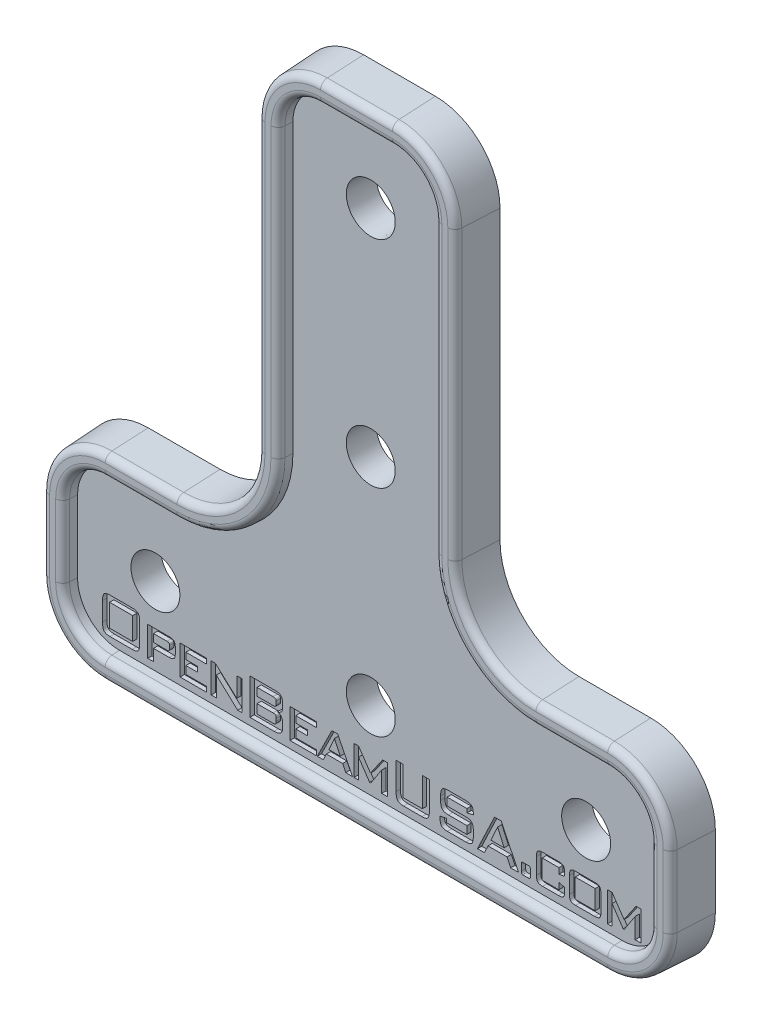
from build123d import *

# Parameters (mm, degrees)
BOSS_EXTRUDE1_DEPTH = 2
FILLET1_R           = 5
SKETCH2_R           = 1.6
CUT_EXTRUDE1_DEPTH  = 38.553295461
MOVE_FACE1_BY       = 0.5
MOVE_FACE1_2_BY     = 0.5
MOVE_FACE1_3_BY     = 0.5
MOVE_FACE1_4_BY     = 0.5
MOVE_FACE1_5_BY     = 0.5
MOVE_FACE1_6_BY     = 0.5
MOVE_FACE1_7_BY     = 0.5
MOVE_FACE1_8_BY     = 0.5
MOVE_FACE1_9_BY     = 0.5
MOVE_FACE1_10_BY    = 0.5
MOVE_FACE1_11_BY    = 0.5
MOVE_FACE1_12_BY    = 0.5
MOVE_FACE1_13_BY    = 0.5
MOVE_FACE1_14_BY    = 0.5
MOVE_FACE1_15_BY    = 0.5
MOVE_FACE1_16_BY    = 0.5
DRAFT1_ANGLE        = -3
BOSS_EXTRUDE3_DEPTH = 1
BOSS_EXTRUDE3_DRAFT = 3
FILLET3_R           = 0.5
CUT_EXTRUDE2_DEPTH  = 0.2
CUT_EXTRUDE2_DRAFT  = -3
SKETCH6_W           = 1.607142857
SKETCH6_H           = 1.5625
SKETCH6_W_2         = 1.383928571
SKETCH6_H_2         = 1.339285714
CUT_EXTRUDE3_DEPTH  = 0.3


with BuildPart() as part:
    # Sketch1 → Boss-Extrude1 (new body)
    with BuildSketch(Plane.XY):
        Polygon((-7.5, 30), (7.5, 30), (7.5, 0), (22.5, 0), (22.5, -15), (-22.5, -15), (-22.5, 0), (-7.5, 0), align=None)
    extrude(amount=BOSS_EXTRUDE1_DEPTH)

    # Fillet1
    fillet1_edges = [part.edges().sort_by_distance(p)[0] for p in [
        (-7.5, 30, 1),
        (7.5, 30, 1),
        (7.5, 0, 1),
        (22.5, 0, 1),
        (22.5, -15, 1),
        (-22.5, -15, 1),
        (-22.5, 0, 1),
        (-7.5, 0, 1),
    ]]
    fillet(fillet1_edges, radius=FILLET1_R)

    # Sketch2 → Cut-Extrude1 (cut, through all)
    with BuildSketch(Plane.XY.offset(2)):
        with Locations((-15, -7.5)):
            Circle(SKETCH2_R)
        with Locations((0, -7.5)):
            Circle(SKETCH2_R)
        with Locations((15, -7.5)):
            Circle(SKETCH2_R)
        with Locations((0, 22.5)):
            Circle(SKETCH2_R)
        with Locations((0, 7.5)):
            Circle(SKETCH2_R)
    extrude(amount=-CUT_EXTRUDE1_DEPTH, mode=Mode.SUBTRACT)

    # Move Face1: a curved face moved inward by 0.5
    add(Solid.thicken(part.faces().sort_by_distance((-8.964466094, 1.464466094, 1))[0], -MOVE_FACE1_BY), mode=Mode.SUBTRACT)

    # Move Face1 2: a face moved inward by 0.5
    extrude(part.faces().sort_by_distance((-15, 0, 1))[0], amount=MOVE_FACE1_2_BY, dir=(0, -1, 0), mode=Mode.SUBTRACT)

    # Move Face1 3: a curved face moved inward by 0.5
    add(Solid.thicken(part.faces().sort_by_distance((-21.035533906, -1.464466094, 1))[0], -MOVE_FACE1_3_BY), mode=Mode.SUBTRACT)

    # Move Face1 4: a face moved inward by 0.5
    extrude(part.faces().sort_by_distance((-22.5, -7.5, 1))[0], amount=MOVE_FACE1_4_BY, dir=(1, 0, 0), mode=Mode.SUBTRACT)

    # Move Face1 5: a curved face moved inward by 0.5
    add(Solid.thicken(part.faces().sort_by_distance((-21.035533906, -13.535533906, 1))[0], -MOVE_FACE1_5_BY), mode=Mode.SUBTRACT)

    # Move Face1 6: a face moved inward by 0.5
    extrude(part.faces().sort_by_distance((0, -15, 1))[0], amount=MOVE_FACE1_6_BY, dir=(0, 1, 0), mode=Mode.SUBTRACT)

    # Move Face1 7: a curved face moved inward by 0.5
    add(Solid.thicken(part.faces().sort_by_distance((21.035533906, -13.535533906, 1))[0], -MOVE_FACE1_7_BY), mode=Mode.SUBTRACT)

    # Move Face1 8: a face moved inward by 0.5
    extrude(part.faces().sort_by_distance((22.5, -7.5, 1))[0], amount=MOVE_FACE1_8_BY, dir=(-1, 0, 0), mode=Mode.SUBTRACT)

    # Move Face1 9: a curved face moved inward by 0.5
    add(Solid.thicken(part.faces().sort_by_distance((21.035533906, -1.464466094, 1))[0], -MOVE_FACE1_9_BY), mode=Mode.SUBTRACT)

    # Move Face1 10: a face moved inward by 0.5
    extrude(part.faces().sort_by_distance((15, 0, 1))[0], amount=MOVE_FACE1_10_BY, dir=(0, -1, 0), mode=Mode.SUBTRACT)

    # Move Face1 11: a curved face moved inward by 0.5
    add(Solid.thicken(part.faces().sort_by_distance((8.964466094, 1.464466094, 1))[0], -MOVE_FACE1_11_BY), mode=Mode.SUBTRACT)

    # Move Face1 12: a face moved inward by 0.5
    extrude(part.faces().sort_by_distance((7.5, 15, 1))[0], amount=MOVE_FACE1_12_BY, dir=(-1, 0, 0), mode=Mode.SUBTRACT)

    # Move Face1 13: a curved face moved inward by 0.5
    add(Solid.thicken(part.faces().sort_by_distance((6.035533906, 28.535533906, 1))[0], -MOVE_FACE1_13_BY), mode=Mode.SUBTRACT)

    # Move Face1 14: a face moved inward by 0.5
    extrude(part.faces().sort_by_distance((0, 30, 1))[0], amount=MOVE_FACE1_14_BY, dir=(0, -1, 0), mode=Mode.SUBTRACT)

    # Move Face1 15: a curved face moved inward by 0.5
    add(Solid.thicken(part.faces().sort_by_distance((-6.035533906, 28.535533906, 1))[0], -MOVE_FACE1_15_BY), mode=Mode.SUBTRACT)

    # Move Face1 16: a face moved inward by 0.5
    extrude(part.faces().sort_by_distance((-7.5, 15, 1))[0], amount=MOVE_FACE1_16_BY, dir=(1, 0, 0), mode=Mode.SUBTRACT)

    # Draft1
    draft1_faces = [part.faces().sort_by_distance(p)[0] for p in [
        (13.4, -7.5, 1),
        (-1.6, 22.5, 1),
        (-1.6, 7.5, 1),
        (-1.6, -7.5, 1),
        (-16.6, -7.5, 1),
        (-20.681980515, -1.818019485, 1),
        (-22, -7.5, 1),
        (-20.681980515, -13.181980515, 1),
        (0, -14.5, 1),
        (20.681980515, -13.181980515, 1),
        (22, -7.5, 1),
        (20.681980515, -1.818019485, 1),
        (15, -0.5, 1),
        (8.610912703, 1.110912703, 1),
        (7, 15, 1),
        (5.681980515, 28.181980515, 1),
        (0, 29.5, 1),
        (-5.681980515, 28.181980515, 1),
        (-7, 15, 1),
        (-8.610912703, 1.110912703, 1),
        (-15, -0.5, 1),
    ]]
    draft(draft1_faces, Plane(origin=(0, 0, 0), x_dir=(-1, 0, 0), z_dir=(0, 0, -1)), DRAFT1_ANGLE)


with BuildPart() as boss_extrude3_tool:
    # Sketch4 → Boss-Extrude3 (with draft: the straight prism first)
    with BuildSketch(Plane.XY.offset(2)):
        with BuildLine():
            Line((-17.5, -14.395184441), (17.5, -14.395184441))
            ThreePointArc((17.5, -14.395184441), (20.607864723, -13.107864723), (21.895184441, -10))
            Line((21.895184441, -10), (21.895184441, -5))
            ThreePointArc((21.895184441, -5), (20.607864723, -1.892135277), (17.5, -0.604815559))
            Line((17.5, -0.604815559), (12.5, -0.604815559))
            ThreePointArc((12.5, -0.604815559), (8.536796911, 1.036796911), (6.895184441, 5))
            Line((6.895184441, 5), (6.895184441, 25))
            ThreePointArc((6.895184441, 25), (5.607864723, 28.107864723), (2.5, 29.395184441))
            Line((2.5, 29.395184441), (-2.5, 29.395184441))
            ThreePointArc((-2.5, 29.395184441), (-5.607864723, 28.107864723), (-6.895184441, 25))
            Line((-6.895184441, 25), (-6.895184441, 5))
            ThreePointArc((-6.895184441, 5), (-8.536796911, 1.036796911), (-12.5, -0.604815559))
            Line((-12.5, -0.604815559), (-17.5, -0.604815559))
            ThreePointArc((-17.5, -0.604815559), (-20.607864723, -1.892135277), (-21.895184441, -5))
            Line((-21.895184441, -5), (-21.895184441, -10))
            ThreePointArc((-21.895184441, -10), (-20.607864723, -13.107864723), (-17.5, -14.395184441))
        make_face()
        with BuildLine():
            Line((-17.5, -12.921388331), (17.5, -12.921388331))
            ThreePointArc((17.5, -12.921388331), (19.565733499, -12.065733499), (20.421388331, -10))
            Line((20.421388331, -10), (20.421388331, -5))
            ThreePointArc((20.421388331, -5), (19.565733499, -2.934266501), (17.5, -2.078611669))
            Line((17.5, -2.078611669), (12.5, -2.078611669))
            ThreePointArc((12.5, -2.078611669), (7.494665688, -0.005334312), (5.421388331, 5))
            Line((5.421388331, 5), (5.421388331, 25))
            ThreePointArc((5.421388331, 25), (4.565733499, 27.065733499), (2.5, 27.921388331))
            Line((2.5, 27.921388331), (-2.5, 27.921388331))
            ThreePointArc((-2.5, 27.921388331), (-4.565733499, 27.065733499), (-5.421388331, 25))
            Line((-5.421388331, 25), (-5.421388331, 5))
            ThreePointArc((-5.421388331, 5), (-7.494665688, -0.005334312), (-12.5, -2.078611669))
            Line((-12.5, -2.078611669), (-17.5, -2.078611669))
            ThreePointArc((-17.5, -2.078611669), (-19.565733499, -2.934266501), (-20.421388331, -5))
            Line((-20.421388331, -5), (-20.421388331, -10))
            ThreePointArc((-20.421388331, -10), (-19.565733499, -12.065733499), (-17.5, -12.921388331))
        make_face(mode=Mode.SUBTRACT)
    extrude(amount=BOSS_EXTRUDE3_DEPTH)
    # Boss-Extrude3: the draft: its side faces are tilted about the plane it starts from
    boss_extrude3_sides = [boss_extrude3_tool.faces().sort_by_distance(p)[0] for p in [
        (-20.607864723, -1.892135277, 2.5),
        (-21.895184441, -7.5, 2.5),
        (-20.607864723, -13.107864723, 2.5),
        (0, -14.395184441, 2.5),
        (20.607864723, -13.107864723, 2.5),
        (21.895184441, -7.5, 2.5),
        (20.607864723, -1.892135277, 2.5),
        (15, -0.604815559, 2.5),
        (8.536796911, 1.036796911, 2.5),
        (6.895184441, 15, 2.5),
        (5.607864723, 28.107864723, 2.5),
        (0, 29.395184441, 2.5),
        (-5.607864723, 28.107864723, 2.5),
        (-6.895184441, 15, 2.5),
        (-8.536796911, 1.036796911, 2.5),
        (-15, -0.604815559, 2.5),
        (-15, -2.078611669, 2.5),
        (-7.494665688, -0.005334312, 2.5),
        (-5.421388331, 15, 2.5),
        (-4.565733499, 27.065733499, 2.5),
        (0, 27.921388331, 2.5),
        (4.565733499, 27.065733499, 2.5),
        (5.421388331, 15, 2.5),
        (7.494665688, -0.005334312, 2.5),
        (15, -2.078611669, 2.5),
        (19.565733499, -2.934266501, 2.5),
        (20.421388331, -7.5, 2.5),
        (19.565733499, -12.065733499, 2.5),
        (0, -12.921388331, 2.5),
        (-19.565733499, -12.065733499, 2.5),
        (-20.421388331, -7.5, 2.5),
        (-19.565733499, -2.934266501, 2.5),
    ]]
    draft(boss_extrude3_sides, Plane.XY.offset(2), BOSS_EXTRUDE3_DRAFT)


with BuildPart() as part_1:
    add(part.part)

    # Boss-Extrude3: add boss_extrude3_tool
    add(boss_extrude3_tool.part)

    # Fillet3
    fillet3_edges = [part_1.edges().sort_by_distance(p)[0] for p in [
        (-20.570806827, -13.070806827, 3),
        (0, -14.342776662, 3),
        (20.570806827, -13.070806827, 3),
        (21.842776662, -7.5, 3),
        (20.570806827, -1.929193173, 3),
        (15, -0.657223338, 3),
        (8.499739015, 0.999739015, 3),
        (6.842776662, 15, 3),
        (5.570806827, 28.070806827, 3),
        (0, 29.342776662, 3),
        (-5.570806827, 28.070806827, 3),
        (-6.842776662, 15, 3),
        (-8.499739015, 0.999739015, 3),
        (-15, -0.657223338, 3),
        (-20.570806827, -1.929193173, 3),
        (-21.842776662, -7.5, 3),
        (-19.602791396, -12.102791396, 3),
        (0, -12.97379611, 3),
        (19.602791396, -12.102791396, 3),
        (20.47379611, -7.5, 3),
        (19.602791396, -2.897208604, 3),
        (15, -2.02620389, 3),
        (7.531723584, 0.031723584, 3),
        (5.47379611, 15, 3),
        (4.602791396, 27.102791396, 3),
        (0, 27.97379611, 3),
        (-4.602791396, 27.102791396, 3),
        (-5.47379611, 15, 3),
        (-7.531723584, 0.031723584, 3),
        (-15, -2.02620389, 3),
        (-19.602791396, -2.897208604, 3),
        (-20.47379611, -7.5, 3),
    ]]
    fillet(fillet3_edges, radius=FILLET3_R)


with BuildPart() as cut_extrude2_tool:
    # Sketch5 → Cut-Extrude2 (with draft: the straight prism first)
    with BuildSketch(Plane(origin=(0, 0, 0), x_dir=(-1, 0, 0), z_dir=(0, 0, -1))):
        with BuildLine():
            Line((-14.5, -13.8), (14.5, -13.8))
            ThreePointArc((14.5, -13.8), (14.853553391, -13.653553391), (15, -13.3))
            Line((15, -13.3), (15, -10.3))
            ThreePointArc((15, -10.3), (14.853553391, -9.946446609), (14.5, -9.8))
            Line((14.5, -9.8), (-14.5, -9.8))
            ThreePointArc((-14.5, -9.8), (-14.853553391, -9.946446609), (-15, -10.3))
            Line((-15, -10.3), (-15, -13.3))
            ThreePointArc((-15, -13.3), (-14.853553391, -13.653553391), (-14.5, -13.8))
        make_face()
    extrude(amount=-CUT_EXTRUDE2_DEPTH)
    # Cut-Extrude2: the draft: its side faces are tilted about the plane it starts from
    cut_extrude2_sides = [cut_extrude2_tool.faces().sort_by_distance(p)[0] for p in [
        (0, -13.8, 0.1),
        (-14.853553391, -13.653553391, 0.1),
        (-15, -11.8, 0.1),
        (-14.853553391, -9.946446609, 0.1),
        (0, -9.8, 0.1),
        (14.853553391, -9.946446609, 0.1),
        (15, -11.8, 0.1),
        (14.853553391, -13.653553391, 0.1),
    ]]
    draft(cut_extrude2_sides, Plane(origin=(0, 0, 0), x_dir=(-1, 0, 0), z_dir=(0, 0, -1)), CUT_EXTRUDE2_DRAFT)


with BuildPart() as part_2:
    add(part_1.part)

    # Cut-Extrude2: cut by cut_extrude2_tool
    add(cut_extrude2_tool.part, mode=Mode.SUBTRACT)

    # Sketch6 → Cut-Extrude3 (cut)
    with BuildSketch(Plane.XY.offset(2)):
        with BuildLine():
            add(Edge.make_bspline(
                [(-18.683035714, -10.51011601), (-18.682938002, -10.482896819), (-18.682750693, -10.430719031), (-18.676668044, -10.356042819), (-18.668860697, -10.287926096), (-18.656684431, -10.226526586), (-18.643031263, -10.171215857), (-18.623628363, -10.123356935), (-18.602261682, -10.081592118), (-18.57683028, -10.045679654), (-18.545847467, -10.01549167), (-18.508789269, -9.990400409), (-18.46597857, -9.968617372), (-18.416580048, -9.951568957), (-18.361320255, -9.937537726), (-18.299893333, -9.928095322), (-18.232289845, -9.922620499), (-18.185232384, -9.921811984), (-18.160574777, -9.921388331)],
                knots=[0, 0, 0, 0, 1.403573437, 2.690578007, 3.862923789, 4.937964027, 5.918444779, 6.796020214, 7.595440406, 8.334448064, 9.055422419, 9.814027648, 10.634759978, 11.526322857, 12.50379092, 13.57259004, 14.728063101, 16, 16, 16, 16], degree=3))
            Line((-18.160574777, -9.921388331), (-16.618303571, -9.921388331))
            add(Edge.make_bspline(
                [(-16.618303571, -9.921388331), (-16.593646851, -9.921821445), (-16.546359359, -9.922652086), (-16.47851397, -9.928042886), (-16.416866585, -9.937552288), (-16.361581808, -9.951531158), (-16.312067564, -9.968807094), (-16.268818434, -9.990195221), (-16.231663242, -10.015520924), (-16.200589368, -10.045644028), (-16.175401388, -10.081803336), (-16.152770043, -10.122971899), (-16.134936302, -10.1715459), (-16.119750579, -10.226353255), (-16.108035577, -10.28796068), (-16.100083866, -10.356032245), (-16.094044728, -10.430722068), (-16.09385104, -10.48289786), (-16.09375, -10.51011601)],
                knots=[0, 0, 0, 0, 1.269785572, 2.435237667, 3.502229043, 4.478043838, 5.368098746, 6.198135559, 6.9554577, 7.675212615, 8.41297033, 9.216677895, 10.088421144, 11.070387939, 12.143609877, 13.313972779, 14.598800537, 16, 16, 16, 16], degree=3))
            Line((-16.09375, -10.51011601), (-16.09375, -11.811036769))
            add(Edge.make_bspline(
                [(-16.09375, -11.811036769), (-16.093842278, -11.839417739), (-16.09401872, -11.893684241), (-16.100160957, -11.971615929), (-16.107923834, -12.042494992), (-16.119768025, -12.106636793), (-16.134983627, -12.163512713), (-16.152647685, -12.213987832), (-16.175226782, -12.256626432), (-16.200584268, -12.293600425), (-16.231614851, -12.324447097), (-16.268765478, -12.35050105), (-16.312034652, -12.372539497), (-16.361440049, -12.390711436), (-16.416882029, -12.404519647), (-16.478547615, -12.413833116), (-16.546317858, -12.420380788), (-16.593639586, -12.421043123), (-16.618303571, -12.421388331)],
                knots=[0, 0, 0, 0, 1.431764632, 2.737639174, 3.942781974, 5.02906717, 6.025299976, 6.912532689, 7.72083079, 8.453349384, 9.16691991, 9.91579719, 10.734504626, 11.610727997, 12.566975227, 13.612570717, 14.755676853, 16, 16, 16, 16], degree=3))
            Line((-16.618303571, -12.421388331), (-18.160574777, -12.421388331))
            add(Edge.make_bspline(
                [(-18.160574777, -12.421388331), (-18.185239843, -12.421053786), (-18.232332055, -12.420415051), (-18.299858951, -12.413778337), (-18.36130513, -12.404534983), (-18.416721056, -12.39067324), (-18.466016648, -12.372733543), (-18.508837175, -12.350292386), (-18.545896228, -12.324476536), (-18.576835987, -12.293565989), (-18.602437267, -12.256831275), (-18.623739569, -12.213611433), (-18.642993476, -12.163833364), (-18.656664691, -12.106469119), (-18.668974999, -12.042529082), (-18.676590443, -11.971605588), (-18.682776858, -11.893687213), (-18.682946824, -11.83941876), (-18.683035714, -11.811036769)],
                knots=[0, 0, 0, 0, 1.246375741, 2.37966474, 3.42698501, 4.384809634, 5.262478393, 6.072109836, 6.82222244, 7.536970048, 8.27069698, 9.074935671, 9.967741802, 10.962637047, 12.050714143, 13.257844907, 14.565873577, 16, 16, 16, 16], degree=3))
            Line((-18.683035714, -11.811036769), (-18.683035714, -10.51011601))
        make_face()
        with Locations((-17.388392858, -11.149066903)):
            Rectangle(SKETCH6_W, SKETCH6_H, mode=Mode.SUBTRACT)
        with BuildLine():
            Line((-15.535714286, -12.421388331), (-15.535714286, -10.367816903))
            Line((-15.535714286, -10.367816903), (-14.029715402, -10.367816903))
            add(Edge.make_bspline(
                [(-14.029715402, -10.367816903), (-13.995423097, -10.368539056), (-13.931618582, -10.369882701), (-13.843548193, -10.388389773), (-13.76975323, -10.416602804), (-13.710808728, -10.459570634), (-13.666606985, -10.516609772), (-13.63694694, -10.588263693), (-13.619168575, -10.67387452), (-13.617150642, -10.735791272), (-13.616071429, -10.768905072)],
                knots=[0, 0, 0, 0, 1.229947315, 2.288449038, 3.21776736, 4.048244043, 4.875520742, 5.777278643, 6.811262717, 8, 8, 8, 8], degree=3))
            Line((-13.616071429, -10.768905072), (-13.616071429, -11.216728733))
            add(Edge.make_bspline(
                [(-13.616071429, -11.216728733), (-13.61713941, -11.249840567), (-13.619129003, -11.311526162), (-13.637004149, -11.397243648), (-13.667259143, -11.468686782), (-13.711509006, -11.52635012), (-13.770938209, -11.568616699), (-13.844372756, -11.597454165), (-13.932113653, -11.615653184), (-13.995666115, -11.617062069), (-14.029715402, -11.617816903)],
                knots=[0, 0, 0, 0, 1.189703839, 2.216355318, 3.129857055, 3.957806409, 4.795702339, 5.718039216, 6.7774016, 8, 8, 8, 8], degree=3))
            Line((-14.029715402, -11.617816903), (-15.133928571, -11.617816903))
            Line((-15.133928571, -11.617816903), (-15.133928571, -12.421388331))
            Line((-15.133928571, -12.421388331), (-15.535714286, -12.421388331))
        make_face()
        with BuildLine():
            Line((-14.203404018, -10.72495976), (-15.133928571, -10.72495976))
            Line((-15.133928571, -10.72495976), (-15.133928571, -11.260674045))
            Line((-15.133928571, -11.260674045), (-14.203404018, -11.260674045))
            add(Edge.make_bspline(
                [(-14.203404018, -11.260674045), (-14.187098835, -11.260411914), (-14.157096885, -11.259929586), (-14.115874448, -11.253123203), (-14.082698889, -11.241865943), (-14.056496441, -11.22503593), (-14.038862603, -11.201230006), (-14.025790126, -11.172314024), (-14.019621299, -11.136752914), (-14.018473493, -11.11118051), (-14.017857143, -11.097448599)],
                knots=[0, 0, 0, 0, 1.352116432, 2.487928597, 3.45245427, 4.244622693, 5.028283095, 5.874769735, 6.858790467, 8, 8, 8, 8], degree=3))
            Line((-14.017857143, -11.097448599), (-14.017857143, -10.888185206))
            add(Edge.make_bspline(
                [(-14.017857143, -10.888185206), (-14.018466943, -10.874447349), (-14.01960255, -10.848863871), (-14.025849613, -10.813373783), (-14.038604854, -10.784405633), (-14.05696494, -10.76134583), (-14.082395639, -10.743581231), (-14.115935147, -10.732589069), (-14.157077073, -10.725678609), (-14.187091859, -10.725212873), (-14.203404018, -10.72495976)],
                knots=[0, 0, 0, 0, 1.141800926, 2.126331593, 2.973256896, 3.742199929, 4.545756613, 5.510782118, 6.64718288, 8, 8, 8, 8], degree=3))
        make_face(mode=Mode.SUBTRACT)
        Polygon((-13.28125, -12.421388331), (-13.28125, -10.367816903), (-11.450892857, -10.367816903), (-11.450892857, -10.72495976), (-12.879464286, -10.72495976), (-12.879464286, -11.171388331), (-12.075892857, -11.171388331), (-12.075892857, -11.528531188), (-12.879464286, -11.528531188), (-12.879464286, -12.064245474), (-11.450892857, -12.064245474), (-11.450892857, -12.421388331), align=None)
        Polygon((-11.116071429, -12.421388331), (-11.116071429, -10.367816903), (-10.821707589, -10.367816903), (-9.330357143, -11.731516679), (-9.330357143, -10.367816903), (-8.973214286, -10.367816903), (-8.973214286, -12.421388331), (-9.269670759, -12.421388331), (-10.758928571, -11.036762215), (-10.758928571, -12.421388331), align=None)
        with BuildLine():
            Line((-8.415178571, -12.421388331), (-8.415178571, -9.921388331))
            Line((-8.415178571, -9.921388331), (-6.604352679, -9.921388331))
            add(Edge.make_bspline(
                [(-6.604352679, -9.921388331), (-6.584578843, -9.921834875), (-6.546344475, -9.922698306), (-6.490993159, -9.928039701), (-6.439967327, -9.937982556), (-6.392984602, -9.950745963), (-6.350485334, -9.96859511), (-6.312122888, -9.989884555), (-6.278270641, -10.015636971), (-6.247499297, -10.044225626), (-6.221859971, -10.078333565), (-6.199342826, -10.116212883), (-6.180626562, -10.158719559), (-6.16430305, -10.205449169), (-6.152784019, -10.257462736), (-6.1448266, -10.313921043), (-6.13872257, -10.37466268), (-6.138505034, -10.416628349), (-6.138392857, -10.438268911)],
                knots=[0, 0, 0, 0, 1.179053587, 2.27979888, 3.310209753, 4.275627239, 5.176695408, 6.051906754, 6.883661987, 7.707291014, 8.547436998, 9.417583548, 10.329674368, 11.311670144, 12.364223081, 13.499348066, 14.710481303, 16, 16, 16, 16], degree=3))
            Line((-6.138392857, -10.438268911), (-6.138392857, -10.712403956))
            add(Edge.make_bspline(
                [(-6.138392857, -10.712403956), (-6.139201585, -10.740664602), (-6.140751158, -10.794813763), (-6.159801787, -10.871364096), (-6.188653758, -10.939999278), (-6.231476997, -10.9984646), (-6.284875183, -11.04779488), (-6.349361396, -11.086101447), (-6.424010981, -11.11446387), (-6.477873721, -11.124365422), (-6.505998884, -11.129535653)],
                knots=[0, 0, 0, 0, 1.098733523, 2.105242008, 3.054667811, 3.982622784, 4.906010345, 5.869427447, 6.887492557, 8, 8, 8, 8], degree=3))
            add(Edge.make_bspline(
                [(-6.505998884, -11.129535653), (-6.478036354, -11.135503517), (-6.424069928, -11.147021228), (-6.349494996, -11.180530422), (-6.285840082, -11.227562783), (-6.231981261, -11.286146859), (-6.190215279, -11.356411535), (-6.158931917, -11.436113578), (-6.142041656, -11.526206522), (-6.139644104, -11.589151907), (-6.138392857, -11.62200217)],
                knots=[0, 0, 0, 0, 1.013460027, 1.955932307, 2.877588656, 3.806945104, 4.76292404, 5.764334755, 6.833239427, 8, 8, 8, 8], degree=3))
            Line((-6.138392857, -11.62200217), (-6.138392857, -11.935199715))
            add(Edge.make_bspline(
                [(-6.138392857, -11.935199715), (-6.138719134, -11.95521589), (-6.1393511, -11.993985259), (-6.146352988, -12.050089823), (-6.158290901, -12.101885834), (-6.174184983, -12.150022339), (-6.195462804, -12.19402501), (-6.220131016, -12.234909748), (-6.250938229, -12.270878361), (-6.285794672, -12.303013122), (-6.32562112, -12.331371608), (-6.370173139, -12.355556185), (-6.41960395, -12.375811734), (-6.47355595, -12.392422759), (-6.532276629, -12.405800235), (-6.595779264, -12.414401622), (-6.66400309, -12.420183393), (-6.71106383, -12.420976607), (-6.735491071, -12.421388331)],
                knots=[0, 0, 0, 0, 1.08782081, 2.107002258, 3.066832627, 3.974287218, 4.856380914, 5.719335199, 6.562621095, 7.421491684, 8.291454475, 9.213583009, 10.171413382, 11.190986747, 12.279688622, 13.441734262, 14.672112383, 16, 16, 16, 16], degree=3))
            Line((-6.735491071, -12.421388331), (-8.415178571, -12.421388331))
        make_face()
        with BuildLine():
            Line((-6.809430804, -10.367816903), (-7.924107143, -10.367816903))
            Line((-7.924107143, -10.367816903), (-7.924107143, -10.903531188))
            Line((-7.924107143, -10.903531188), (-6.809430804, -10.903531188))
            add(Edge.make_bspline(
                [(-6.809430804, -10.903531188), (-6.789868986, -10.903287406), (-6.753850642, -10.902838541), (-6.704705771, -10.895868934), (-6.664727575, -10.885532078), (-6.633451466, -10.869144346), (-6.610525171, -10.846199776), (-6.594844818, -10.816925235), (-6.585991347, -10.781273052), (-6.585228551, -10.755471654), (-6.584821429, -10.741700831)],
                knots=[0, 0, 0, 0, 1.458061766, 2.684667078, 3.694961047, 4.525618309, 5.286113602, 6.078010599, 6.974188284, 8, 8, 8, 8], degree=3))
            Line((-6.584821429, -10.741700831), (-6.584821429, -10.52964726))
            add(Edge.make_bspline(
                [(-6.584821429, -10.52964726), (-6.585215601, -10.516102183), (-6.585953486, -10.490746024), (-6.594997769, -10.455637651), (-6.610492176, -10.426504554), (-6.633624093, -10.40365479), (-6.664600507, -10.386469448), (-6.704601516, -10.375280427), (-6.753863487, -10.36857796), (-6.789873506, -10.368084762), (-6.809430804, -10.367816903)],
                knots=[0, 0, 0, 0, 1.011123078, 1.892805606, 2.686758123, 3.449227428, 4.290532683, 5.308364354, 6.538153555, 8, 8, 8, 8], degree=3))
        make_face(mode=Mode.SUBTRACT)
        with BuildLine():
            Line((-6.809430804, -11.34995976), (-7.924107143, -11.34995976))
            Line((-7.924107143, -11.34995976), (-7.924107143, -11.97495976))
            Line((-7.924107143, -11.97495976), (-6.809430804, -11.97495976))
            add(Edge.make_bspline(
                [(-6.809430804, -11.97495976), (-6.78912971, -11.974729537), (-6.751959866, -11.974308016), (-6.701848603, -11.964050408), (-6.661008099, -11.950556293), (-6.630050641, -11.927619568), (-6.609123919, -11.895827935), (-6.594863374, -11.856463039), (-6.585878103, -11.808409349), (-6.585191715, -11.773414396), (-6.584821429, -11.754535653)],
                knots=[0, 0, 0, 0, 1.312342557, 2.402804986, 3.304020979, 4.078546667, 4.847629795, 5.734752509, 6.777965855, 8, 8, 8, 8], degree=3))
            Line((-6.584821429, -11.754535653), (-6.584821429, -11.568291233))
            add(Edge.make_bspline(
                [(-6.584821429, -11.568291233), (-6.585200764, -11.549416114), (-6.585903926, -11.514427881), (-6.594743125, -11.466546068), (-6.609130884, -11.427679287), (-6.630070466, -11.396444881), (-6.661397726, -11.374656265), (-6.701546197, -11.359680216), (-6.752105393, -11.35100656), (-6.789165763, -11.350329813), (-6.809430804, -11.34995976)],
                knots=[0, 0, 0, 0, 1.227068129, 2.274578833, 3.151237288, 3.911086288, 4.679771909, 5.590123259, 6.682251448, 8, 8, 8, 8], degree=3))
        make_face(mode=Mode.SUBTRACT)
        Polygon((-5.625, -12.421388331), (-5.625, -10.367816903), (-3.794642857, -10.367816903), (-3.794642857, -10.72495976), (-5.223214286, -10.72495976), (-5.223214286, -11.171388331), (-4.419642857, -11.171388331), (-4.419642857, -11.528531188), (-5.223214286, -11.528531188), (-5.223214286, -12.064245474), (-3.794642857, -12.064245474), (-3.794642857, -12.421388331), align=None)
        Polygon((-3.727678571, -12.421388331), (-2.709263393, -10.367816903), (-2.306780134, -10.367816903), (-1.272321429, -12.421388331), (-1.741768973, -12.421388331), (-1.958007812, -11.97495976), (-3.093610491, -11.97495976), (-3.30984933, -12.421388331), align=None)
        Polygon((-2.915039062, -11.617816903), (-2.128208705, -11.617816903), (-2.52859933, -10.746583644), align=None, mode=Mode.SUBTRACT)
        Polygon((-1.160714286, -12.421388331), (-1.160714286, -10.367816903), (-0.848214286, -10.367816903), (-0.017438616, -11.586427394), (0.822405134, -10.367816903), (1.160714286, -10.367816903), (1.160714286, -12.421388331), (0.758928571, -12.421388331), (0.758928571, -11.008162885), (0.000697545, -12.174457528), (-0.080217634, -12.174457528), (-0.848214286, -11.040947483), (-0.848214286, -12.421388331), align=None)
        with BuildLine():
            Line((2.254464286, -9.921388331), (2.254464286, -11.930316903))
            Line((2.254464286, -11.930316903), (3.59375, -11.930316903))
            Line((3.59375, -11.930316903), (3.59375, -9.921388331))
            Line((3.59375, -9.921388331), (4.084821429, -9.921388331))
            Line((4.084821429, -9.921388331), (4.084821429, -11.811036769))
            add(Edge.make_bspline(
                [(4.084821429, -11.811036769), (4.084729151, -11.83941774), (4.08455271, -11.893684242), (4.078410469, -11.971615924), (4.070647603, -12.042495008), (4.058803376, -12.106636741), (4.043587889, -12.163512882), (4.025923466, -12.213987296), (4.003345545, -12.256628171), (3.977984177, -12.293594652), (3.946967658, -12.32446853), (3.909930317, -12.35029481), (3.867103299, -12.37273261), (3.817809766, -12.390674382), (3.762392801, -12.404530974), (3.700719574, -12.413829665), (3.632951625, -12.420381775), (3.585629562, -12.421043461), (3.560965402, -12.421388331)],
                knots=[0, 0, 0, 0, 1.432696721, 2.739421396, 3.945348753, 5.032341128, 6.029222489, 6.917032796, 7.725857105, 8.458852573, 9.172887639, 9.922252443, 10.731076752, 11.60787055, 12.564740304, 13.611016484, 14.75486679, 16, 16, 16, 16], degree=3))
            Line((3.560965402, -12.421388331), (2.28515625, -12.421388331))
            add(Edge.make_bspline(
                [(2.28515625, -12.421388331), (2.260725019, -12.421041479), (2.213867868, -12.420376245), (2.146787965, -12.413857345), (2.085611417, -12.404422129), (2.030586419, -12.390821903), (1.981612193, -12.372601766), (1.938902995, -12.350085944), (1.901310533, -12.324703811), (1.870249293, -12.29356777), (1.844862961, -12.25663627), (1.822292601, -12.2139848), (1.804625834, -12.16351367), (1.789411083, -12.106636498), (1.777566629, -12.042495084), (1.769803833, -11.971615901), (1.763661571, -11.893684249), (1.763485133, -11.839417742), (1.763392857, -11.811036769)],
                knots=[0, 0, 0, 0, 1.23621022, 2.370952548, 3.407995083, 4.367048021, 5.234819768, 6.045489481, 6.806183598, 7.521847799, 8.256515662, 9.067185375, 9.957021301, 10.956177136, 12.045649581, 13.254328369, 14.564034454, 16, 16, 16, 16], degree=3))
            Line((1.763392857, -11.811036769), (1.763392857, -9.921388331))
            Line((1.763392857, -9.921388331), (2.254464286, -9.921388331))
        make_face()
        with BuildLine():
            Line((6.696428571, -10.367816903), (5.3125, -10.367816903))
            Line((5.3125, -10.367816903), (5.3125, -10.903531188))
            Line((5.3125, -10.903531188), (6.63016183, -10.903531188))
            add(Edge.make_bspline(
                [(6.63016183, -10.903531188), (6.654353014, -10.903958949), (6.700479225, -10.904774577), (6.766713326, -10.910183332), (6.826905144, -10.919870583), (6.881304458, -10.93330079), (6.92929363, -10.951844001), (6.971690494, -10.973066465), (7.007619207, -10.999097146), (7.038065694, -11.029410299), (7.063642091, -11.06526319), (7.084974932, -11.107481732), (7.103195036, -11.156136605), (7.117397219, -11.211638562), (7.129343814, -11.273803544), (7.137366908, -11.3428083), (7.142315022, -11.418477621), (7.142671297, -11.471091459), (7.142857143, -11.498536769)],
                knots=[0, 0, 0, 0, 1.251664019, 2.386593346, 3.434812074, 4.403525499, 5.279339231, 6.091802716, 6.849802477, 7.564361493, 8.305564064, 9.118027549, 10.005088541, 10.988481401, 12.078528828, 13.278238635, 14.580229349, 16, 16, 16, 16], degree=3))
            Line((7.142857143, -11.498536769), (7.142857143, -11.820802394))
            add(Edge.make_bspline(
                [(7.142857143, -11.820802394), (7.142670907, -11.848480082), (7.142313758, -11.90155824), (7.137365743, -11.977924663), (7.1293358, -12.047622044), (7.117402599, -12.110490083), (7.103150126, -12.166658376), (7.085162413, -12.215888413), (7.063443653, -12.258367141), (7.038074605, -12.294750102), (7.0078556, -12.325841034), (6.971643631, -12.351775421), (6.929450865, -12.373242409), (6.881137779, -12.390741413), (6.826858606, -12.40421072), (6.766788679, -12.414980112), (6.70046859, -12.42007351), (6.654349355, -12.420935995), (6.63016183, -12.421388331)],
                knots=[0, 0, 0, 0, 1.424071459, 2.730975543, 3.936089492, 5.032008831, 6.021662612, 6.915142695, 7.723221153, 8.470166276, 9.189379185, 9.94328787, 10.751366328, 11.61825191, 12.581736995, 13.626287574, 14.755091461, 16, 16, 16, 16], degree=3))
            Line((6.63016183, -12.421388331), (5.324358259, -12.421388331))
            add(Edge.make_bspline(
                [(5.324358259, -12.421388331), (5.300866876, -12.420931359), (5.255674503, -12.420052242), (5.190533843, -12.414925726), (5.131530179, -12.404487117), (5.078393092, -12.390307101), (5.030932807, -12.373619972), (4.989668753, -12.35157881), (4.954294363, -12.325618915), (4.924073733, -12.294956748), (4.899449082, -12.258298175), (4.878544743, -12.215717937), (4.860436506, -12.166672042), (4.845991982, -12.110563995), (4.835216036, -12.047531968), (4.826837919, -11.97793932), (4.821995382, -11.901554055), (4.821622836, -11.848478648), (4.821428571, -11.820802394)],
                knots=[0, 0, 0, 0, 1.219667072, 2.346377425, 3.388230707, 4.325160294, 5.199674189, 5.993493179, 6.744299279, 7.46984103, 8.21646325, 9.026182912, 9.927525331, 10.925887746, 12.029274189, 13.244992753, 14.563397171, 16, 16, 16, 16], degree=3))
            Line((4.821428571, -11.820802394), (4.821428571, -11.75872092))
            Line((4.821428571, -11.75872092), (5.267857143, -11.66245976))
            Line((5.267857143, -11.66245976), (5.267857143, -11.930316903))
            Line((5.267857143, -11.930316903), (6.696428571, -11.930316903))
            Line((6.696428571, -11.930316903), (6.696428571, -11.394602617))
            Line((6.696428571, -11.394602617), (5.406668527, -11.394602617))
            add(Edge.make_bspline(
                [(5.406668527, -11.394602617), (5.381318621, -11.394142187), (5.332646449, -11.393258156), (5.262625271, -11.38820715), (5.199039968, -11.377517598), (5.141836488, -11.363824902), (5.090670769, -11.346784404), (5.046603427, -11.324170198), (5.008215836, -11.298389637), (4.97572848, -11.267778264), (4.949636871, -11.230568829), (4.926561464, -11.188113753), (4.907738712, -11.138304217), (4.89305814, -11.081840424), (4.880014688, -11.018833425), (4.872516201, -10.948772379), (4.866340152, -10.872018433), (4.86616349, -10.818446253), (4.866071429, -10.790528956)],
                knots=[0, 0, 0, 0, 1.269118906, 2.436725934, 3.510156791, 4.492522834, 5.379601377, 6.202018549, 6.963898946, 7.688320218, 8.421662355, 9.228867506, 10.102094215, 11.078998209, 12.147242463, 13.319481032, 14.603139802, 16, 16, 16, 16], degree=3))
            Line((4.866071429, -10.790528956), (4.866071429, -10.512906188))
            add(Edge.make_bspline(
                [(4.866071429, -10.512906188), (4.866168727, -10.485686466), (4.866356072, -10.43327569), (4.872507781, -10.358146186), (4.880016723, -10.289478223), (4.89301151, -10.227844707), (4.907893802, -10.172615002), (4.926346791, -10.123783283), (4.949852356, -10.082499353), (4.975700358, -10.04602468), (5.008481655, -10.016282414), (5.046389433, -9.990260801), (5.090887408, -9.968693775), (5.141807749, -9.951449339), (5.198979833, -9.937581032), (5.262701901, -9.928047641), (5.332635014, -9.922656793), (5.381314705, -9.921822734), (5.406668527, -9.921388331)],
                knots=[0, 0, 0, 0, 1.377632593, 2.652591195, 3.814954431, 4.872421982, 5.83787301, 6.710181857, 7.506051987, 8.238342604, 8.963022824, 9.733676968, 10.56030012, 11.457594181, 12.451273063, 13.535212947, 14.716266034, 16, 16, 16, 16], degree=3))
            Line((5.406668527, -9.921388331), (6.606445313, -9.921388331))
            add(Edge.make_bspline(
                [(6.606445313, -9.921388331), (6.630871508, -9.921807846), (6.677930234, -9.92261607), (6.745479683, -9.928236239), (6.807133727, -9.936888325), (6.862778268, -9.950065049), (6.91249593, -9.967560204), (6.956687775, -9.988232319), (6.995178384, -10.012838845), (7.027760105, -10.041925314), (7.055736906, -10.075759055), (7.07966266, -10.115155119), (7.098382083, -10.160900236), (7.115935242, -10.211649019), (7.127570867, -10.2686675), (7.13703729, -10.331263883), (7.141354413, -10.399846619), (7.142342132, -10.447566677), (7.142857143, -10.472448599)],
                knots=[0, 0, 0, 0, 1.296779316, 2.498333482, 3.59650498, 4.599589076, 5.528850417, 6.390279385, 7.1847031, 7.945414428, 8.699384315, 9.508162524, 10.381888205, 11.318826147, 12.355238386, 13.465624049, 14.678540085, 16, 16, 16, 16], degree=3))
            Line((7.142857143, -10.472448599), (7.142857143, -10.521974269))
            Line((7.142857143, -10.521974269), (6.696428571, -10.635674045))
            Line((6.696428571, -10.635674045), (6.696428571, -10.367816903))
        make_face()
        Polygon((7.433035714, -12.421388331), (8.618861607, -9.921388331), (9.088309152, -9.921388331), (10.290178571, -12.421388331), (9.742606027, -12.421388331), (9.490792411, -11.885674045), (8.162667411, -11.885674045), (7.918526786, -12.421388331), align=None)
        Polygon((8.370535714, -11.439245474), (9.289202009, -11.439245474), (8.836495536, -10.41106467), align=None, mode=Mode.SUBTRACT)
        with BuildLine():
            Line((10.947265625, -11.66245976), (11.019810268, -11.66245976))
            add(Edge.make_bspline(
                [(11.019810268, -11.66245976), (11.027999823, -11.662762392), (11.043561673, -11.663337456), (11.065175956, -11.670328563), (11.08258162, -11.682608663), (11.096133093, -11.700261925), (11.105761925, -11.72423938), (11.111339898, -11.756185192), (11.115503699, -11.796046072), (11.115871855, -11.825669926), (11.116071429, -11.841728733)],
                knots=[0, 0, 0, 0, 0.842748251, 1.601396187, 2.306979553, 3.007651606, 3.867638522, 4.945078856, 6.343956529, 8, 8, 8, 8], degree=3))
            Line((11.116071429, -11.841728733), (11.116071429, -12.239329179))
            add(Edge.make_bspline(
                [(11.116071429, -12.239329179), (11.115821061, -12.256762807), (11.115366151, -12.28843915), (11.111889735, -12.331172221), (11.104495153, -12.363489524), (11.094282293, -12.38903526), (11.072304395, -12.405401944), (11.040731236, -12.414780928), (10.997929358, -12.420548374), (10.965425103, -12.421087264), (10.947265625, -12.421388331)],
                knots=[0, 0, 0, 0, 1.374312623, 2.49708187, 3.363450868, 3.994280748, 4.60648522, 5.440693098, 6.570166394, 8, 8, 8, 8], degree=3))
            Line((10.947265625, -12.421388331), (10.587332589, -12.421388331))
            add(Edge.make_bspline(
                [(10.587332589, -12.421388331), (10.57911215, -12.421167543), (10.563414316, -12.420745924), (10.542130949, -12.412637095), (10.524295868, -12.400562189), (10.511071218, -12.382066531), (10.501375174, -12.357518538), (10.495874648, -12.325085057), (10.491623159, -12.285016668), (10.491265378, -12.255389684), (10.491071429, -12.239329179)],
                knots=[0, 0, 0, 0, 0.835167186, 1.594843724, 2.294079912, 3.007322222, 3.881508909, 4.972559845, 6.35885371, 8, 8, 8, 8], degree=3))
            Line((10.491071429, -12.239329179), (10.491071429, -11.841728733))
            add(Edge.make_bspline(
                [(10.491071429, -11.841728733), (10.491185364, -11.824740543), (10.491393545, -11.793700027), (10.496404974, -11.752132698), (10.502580946, -11.720057916), (10.512899367, -11.694820591), (10.534824102, -11.678443275), (10.566417608, -11.66906836), (10.609211296, -11.663299276), (10.641716965, -11.662760669), (10.659877232, -11.66245976)],
                knots=[0, 0, 0, 0, 1.350323658, 2.467287249, 3.319663914, 3.956451267, 4.574437317, 5.416523344, 6.556663236, 8, 8, 8, 8], degree=3))
            Line((10.659877232, -11.66245976), (10.947265625, -11.66245976))
        make_face()
        with BuildLine():
            Line((13.102678571, -10.72495976), (11.941964286, -10.72495976))
            Line((11.941964286, -10.72495976), (11.941964286, -12.064245474))
            Line((11.941964286, -12.064245474), (13.102678571, -12.064245474))
            Line((13.102678571, -12.064245474), (13.102678571, -11.617816903))
            Line((13.102678571, -11.617816903), (13.504464286, -11.722448599))
            Line((13.504464286, -11.722448599), (13.504464286, -11.969379403))
            add(Edge.make_bspline(
                [(13.504464286, -11.969379403), (13.504225172, -11.99031379), (13.503767671, -12.030368003), (13.499538173, -12.087890357), (13.492809609, -12.140119142), (13.483089798, -12.187249575), (13.470674771, -12.229345752), (13.455367521, -12.266587161), (13.437475812, -12.298982546), (13.416006342, -12.326280927), (13.390638211, -12.349459178), (13.360454884, -12.368951717), (13.324722096, -12.384775243), (13.284478926, -12.398826014), (13.238845531, -12.409156136), (13.188372016, -12.415523408), (13.133019472, -12.42096738), (13.094324134, -12.421243742), (13.074079241, -12.421388331)],
                knots=[0, 0, 0, 0, 1.360765523, 2.603581789, 3.747306032, 4.781943921, 5.72883076, 6.59625079, 7.394964774, 8.126798441, 8.843648472, 9.619286352, 10.451209517, 11.378590932, 12.386946235, 13.485736962, 14.684570554, 16, 16, 16, 16], degree=3))
            Line((13.074079241, -12.421388331), (11.970563616, -12.421388331))
            add(Edge.make_bspline(
                [(11.970563616, -12.421388331), (11.950549924, -12.42124209), (11.912084521, -12.420961022), (11.856984992, -12.415470427), (11.806665401, -12.409356954), (11.761551407, -12.39839222), (11.720947492, -12.385904984), (11.685973126, -12.368663788), (11.655154862, -12.350065383), (11.629357164, -12.327183074), (11.608057071, -12.299789611), (11.589907352, -12.267712714), (11.573808753, -12.230902429), (11.561508239, -12.188410569), (11.551909277, -12.141036864), (11.545049193, -12.088360305), (11.54090514, -12.03059785), (11.540427022, -11.990313077), (11.540178571, -11.969379403)],
                knots=[0, 0, 0, 0, 1.300519112, 2.499538489, 3.598499497, 4.592285813, 5.514993242, 6.353475823, 7.121088848, 7.849279118, 8.581226198, 9.366937809, 10.240399869, 11.187433448, 12.237034841, 13.380936328, 14.639023597, 16, 16, 16, 16], degree=3))
            Line((11.540178571, -11.969379403), (11.540178571, -10.837961992))
            add(Edge.make_bspline(
                [(11.540178571, -10.837961992), (11.540422204, -10.816098457), (11.540889224, -10.774188029), (11.545065512, -10.714104152), (11.551870055, -10.659572367), (11.561506034, -10.610324339), (11.574107257, -10.566555521), (11.588257803, -10.527526537), (11.606558719, -10.494498), (11.627901872, -10.466197347), (11.653921957, -10.442729532), (11.68429251, -10.422481892), (11.719549987, -10.404794403), (11.760006942, -10.391269143), (11.805577273, -10.380746102), (11.855985006, -10.373509516), (11.911630113, -10.368294661), (11.950321034, -10.367981004), (11.970563616, -10.367816903)],
                knots=[0, 0, 0, 0, 1.39109117, 2.6665966, 3.830090744, 4.8862859, 5.85570128, 6.726752594, 7.521451052, 8.24944347, 8.972003032, 9.739374419, 10.566467661, 11.474192602, 12.446764227, 13.53902846, 14.712451967, 16, 16, 16, 16], degree=3))
            Line((11.970563616, -10.367816903), (13.074079241, -10.367816903))
            add(Edge.make_bspline(
                [(13.074079241, -10.367816903), (13.094320271, -10.367993748), (13.133239923, -10.368333788), (13.189135039, -10.373430511), (13.239961834, -10.380881004), (13.285640939, -10.391011083), (13.325975095, -10.404954297), (13.361014064, -10.42250702), (13.391407177, -10.442496183), (13.416732766, -10.466453594), (13.438117203, -10.494462429), (13.45637492, -10.527537438), (13.470538766, -10.566552115), (13.483135852, -10.610325384), (13.492773102, -10.659572045), (13.499577253, -10.714104251), (13.503753659, -10.774188), (13.504220663, -10.816098448), (13.504464286, -10.837961992)],
                knots=[0, 0, 0, 0, 1.287198977, 2.475038841, 3.56700696, 4.553721921, 5.44723032, 6.274099336, 7.041262687, 7.752792964, 8.480588023, 9.275071037, 10.145886208, 11.115038778, 12.170947598, 13.334126317, 14.609285957, 16, 16, 16, 16], degree=3))
            Line((13.504464286, -10.837961992), (13.504464286, -11.048620474))
            Line((13.504464286, -11.048620474), (13.102678571, -11.126745474))
            Line((13.102678571, -11.126745474), (13.102678571, -10.72495976))
        make_face()
        with BuildLine():
            add(Edge.make_bspline(
                [(13.839285714, -10.836566903), (13.839531531, -10.814935164), (13.840005162, -10.773255892), (13.844199229, -10.713415473), (13.850890376, -10.658845931), (13.860837886, -10.610001509), (13.87216712, -10.566025105), (13.887748874, -10.52792265), (13.904765373, -10.49425395), (13.926379812, -10.466484854), (13.951626709, -10.442483311), (13.982049281, -10.422527223), (14.017248387, -10.404780733), (14.057723015, -10.391272438), (14.103288357, -10.380748428), (14.153925512, -10.373461048), (14.209810233, -10.368325115), (14.248731397, -10.367990781), (14.268973214, -10.367816903)],
                knots=[0, 0, 0, 0, 1.378953156, 2.65691831, 3.822656171, 4.880888125, 5.833901211, 6.712029252, 7.501191106, 8.230587406, 8.94368314, 9.712534349, 10.541222582, 11.450698008, 12.425145169, 13.519515757, 14.70996902, 16, 16, 16, 16], degree=3))
            Line((14.268973214, -10.367816903), (15.597098214, -10.367816903))
            add(Edge.make_bspline(
                [(15.597098214, -10.367816903), (15.617572212, -10.367986699), (15.656725228, -10.368311406), (15.712849404, -10.373438062), (15.76368551, -10.380855488), (15.809549011, -10.39114133), (15.850181047, -10.404837634), (15.885358572, -10.422287324), (15.915149872, -10.442761804), (15.940528416, -10.466207409), (15.961019682, -10.494726374), (15.979473919, -10.527488492), (15.99335749, -10.566380739), (16.006492346, -10.609735206), (16.014797684, -10.658979832), (16.021991513, -10.713387801), (16.026032445, -10.773263736), (16.026528342, -10.814937844), (16.026785714, -10.836566903)],
                knots=[0, 0, 0, 0, 1.303957653, 2.493595769, 3.587217, 4.575425732, 5.484278406, 6.312399205, 7.068487553, 7.781095004, 8.501055435, 9.296741204, 10.168874688, 11.125259206, 12.179961346, 13.344900983, 14.621991065, 16, 16, 16, 16], degree=3))
            Line((16.026785714, -10.836566903), (16.026785714, -11.967984313))
            add(Edge.make_bspline(
                [(16.026785714, -11.967984313), (16.026540726, -11.988918301), (16.026069271, -12.029203676), (16.021862838, -12.087192043), (16.015107323, -12.140109291), (16.00551021, -12.187735372), (15.992989067, -12.230043193), (15.977687664, -12.267279749), (15.959807331, -12.299697679), (15.938292406, -12.326918964), (15.91318614, -12.350296132), (15.882351626, -12.36863633), (15.84760064, -12.385749927), (15.807110535, -12.398643438), (15.761894888, -12.409232126), (15.711381768, -12.415500344), (15.656041105, -12.420974034), (15.617344021, -12.421246027), (15.597098214, -12.421388331)],
                knots=[0, 0, 0, 0, 1.358729287, 2.614739322, 3.771714693, 4.819583083, 5.76505301, 6.631175042, 7.428693838, 8.159432396, 8.875209741, 9.641555356, 10.478653514, 11.385506362, 12.392352772, 13.489499279, 14.686538949, 16, 16, 16, 16], degree=3))
            Line((15.597098214, -12.421388331), (14.268973214, -12.421388331))
            add(Edge.make_bspline(
                [(14.268973214, -12.421388331), (14.248726884, -12.421243249), (14.209797041, -12.420964283), (14.154004917, -12.4154511), (14.103202503, -12.409432552), (14.057873077, -12.398383258), (14.017250768, -12.385920341), (13.982334066, -12.368617246), (13.951475073, -12.350307649), (13.926432903, -12.326891632), (13.904746413, -12.299890785), (13.887905375, -12.267042928), (13.872131201, -12.230201782), (13.860832193, -12.18758336), (13.85087568, -12.140136744), (13.844235431, -12.08718371), (13.839994556, -12.029206036), (13.839528103, -11.988919108), (13.839285714, -11.967984313)],
                knots=[0, 0, 0, 0, 1.311979051, 2.52268621, 3.63352962, 4.624555635, 5.54470019, 6.380853836, 7.146334771, 7.861304492, 8.591218546, 9.380528245, 10.245673017, 11.185854933, 12.232540996, 13.388210932, 14.64280379, 16, 16, 16, 16], degree=3))
            Line((13.839285714, -11.967984313), (13.839285714, -10.836566903))
        make_face()
        with Locations((14.933035715, -11.394602617)):
            Rectangle(SKETCH6_W_2, SKETCH6_H_2, mode=Mode.SUBTRACT)
        Polygon((16.495535714, -12.421388331), (16.495535714, -10.367816903), (16.808035714, -10.367816903), (17.638811384, -11.586427394), (18.478655134, -10.367816903), (18.816964286, -10.367816903), (18.816964286, -12.421388331), (18.415178571, -12.421388331), (18.415178571, -11.008162885), (17.656947545, -12.174457528), (17.576032366, -12.174457528), (16.808035714, -11.040947483), (16.808035714, -12.421388331), align=None)
    extrude(amount=-CUT_EXTRUDE3_DEPTH, mode=Mode.SUBTRACT)


solid = part_2.part
